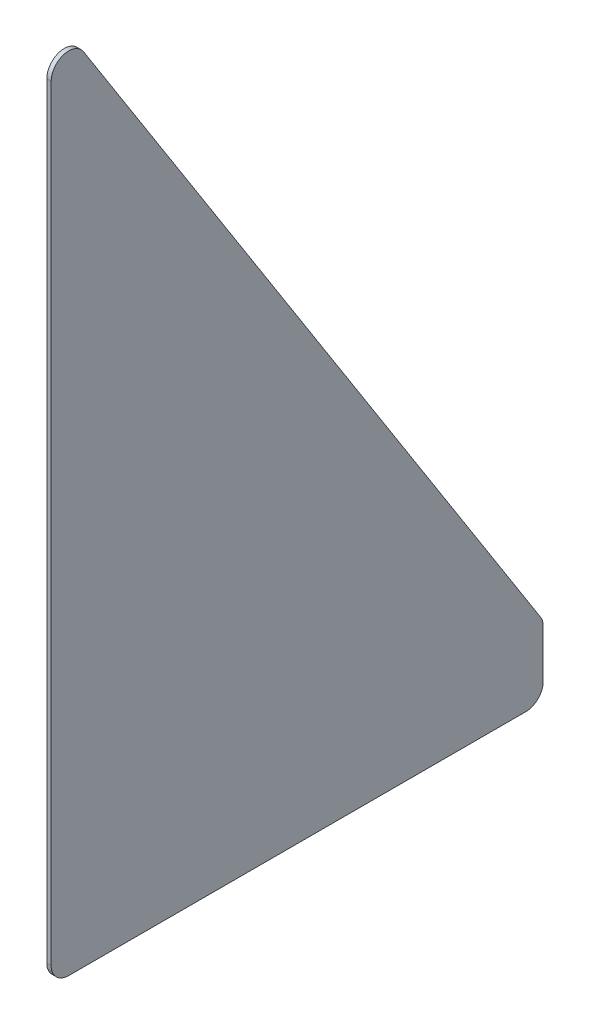
from build123d import *

# Parameters (mm, degrees)
SKETCH1_W           = 1.5875
SKETCH1_H           = 177.8
BOSS_EXTRUDE1_DEPTH = 304.8
CUT_EXTRUDE1_DEPTH  = 1.5875
FILLET1_R           = 6.35


with BuildPart() as part:
    # Sketch1 → Boss-Extrude1 (new body)
    with BuildSketch(Plane(origin=(0, 0, 0), x_dir=(1, 0, 0), z_dir=(0, 1, 0))):
        with Locations((0.79375, 88.9)):
            Rectangle(SKETCH1_W, SKETCH1_H)
    extrude(amount=BOSS_EXTRUDE1_DEPTH)

    # Sketch2 → Cut-Extrude1 (cut)
    with BuildSketch(Plane.ZY):
        Polygon((-177.8, 25.4), (0, 304.8), (-177.8, 304.8), align=None)
    extrude(amount=-CUT_EXTRUDE1_DEPTH, mode=Mode.SUBTRACT)

    # Fillet1
    fillet1_edges = [part.edges().sort_by_distance(p)[0] for p in [
        (0.79375, 25.4, -177.8),
        (0.79375, 304.8, 0),
        (0.79375, 0, -177.8),
        (0.79375, 0, 0),
    ]]
    fillet(fillet1_edges, radius=FILLET1_R)


solid = part.part
